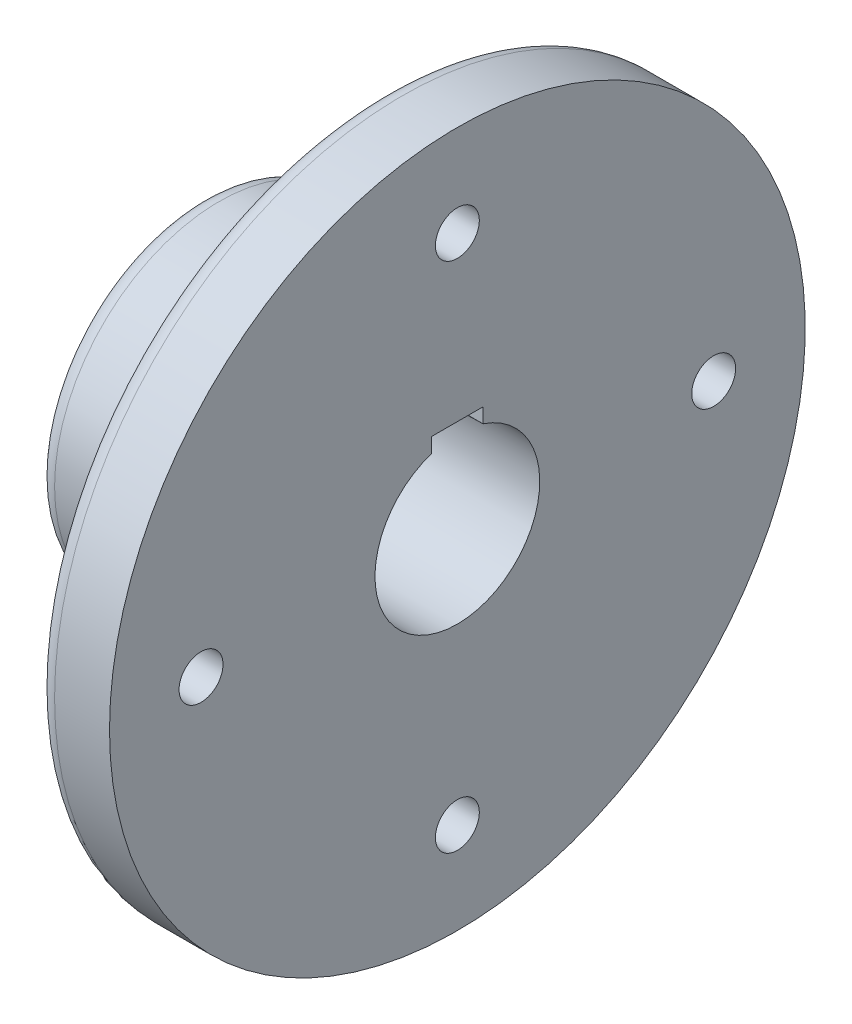
from build123d import *

# Parameters (mm, degrees)
SKETCH10_R         = 6
CUT_EXTRUDE2_DEPTH = 184.098334236
CUT_EXTRUDE4_DEPTH = 184.098334236
CUT_EXTRUDE4_DRAFT = -0.57


with BuildPart() as part:
    # Sketch2 → Revolve1 (revolve)
    with BuildSketch(Plane(origin=(0, 0, 0), x_dir=(1, 0, 0), z_dir=(0, 1, 0))):
        with BuildLine():
            Line((0, 22.5), (0, 5))
            ThreePointArc((0, 5), (1.464466094, 1.464466094), (5, 0))
            Line((5, 0), (45, 0))
            ThreePointArc((45, 0), (48.535533906, -1.464466094), (50, -5))
            Line((50, -5), (50, -45))
            ThreePointArc((50, -45), (51.464466094, -48.535533906), (55, -50))
            Line((55, -50), (70, -50))
            Line((70, -50), (70, 22.5))
            Line((70, 22.5), (0, 22.5))
        make_face()
    revolve(axis=Axis((0, 0, -45), (1, 0, 0)))

    # Sketch10 → Cut-Extrude2 (cut, through all)
    with BuildSketch(Plane(origin=(70, 0, 0), x_dir=(0, 0, -1), z_dir=(1, 0, 0))):
        with Locations((45, -70)):
            Circle(SKETCH10_R)
        with Locations((-25, 0)):
            Circle(SKETCH10_R)
        with Locations((45, 70)):
            Circle(SKETCH10_R)
        with Locations((115, 0)):
            Circle(SKETCH10_R)
    extrude(amount=-CUT_EXTRUDE2_DEPTH, mode=Mode.SUBTRACT)


with BuildPart() as cut_extrude4_tool:
    # Sketch11 → Cut-Extrude4 (with draft: the straight prism first)
    with BuildSketch(Plane(origin=(70, 0, 0), x_dir=(0, 0, -1), z_dir=(1, 0, 0))):
        Polygon((38, 25.4), (38, 21.38340478), (38, 21.284496071), (52, 21.38340478), (52, 25.4), (45, 25.4), align=None)
    extrude(amount=-CUT_EXTRUDE4_DEPTH)
    # Cut-Extrude4: the draft: its side faces are tilted about the plane it starts from
    cut_extrude4_sides = [cut_extrude4_tool.faces().sort_by_distance(p)[0] for p in [
        (-22.049167118, 23.342248035, -38),
        (-22.049167118, 23.39170239, -52),
        (-22.049167118, 21.333950426, -45),
        (-22.049167118, 25.4, -45),
    ]]
    draft(cut_extrude4_sides, Plane(origin=(70, 0, 0), x_dir=(0, 0, -1), z_dir=(1, 0, 0)), CUT_EXTRUDE4_DRAFT)


with BuildPart() as part_1:
    add(part.part)

    # Cut-Extrude4: cut by cut_extrude4_tool
    add(cut_extrude4_tool.part, mode=Mode.SUBTRACT)


solid = part_1.part
